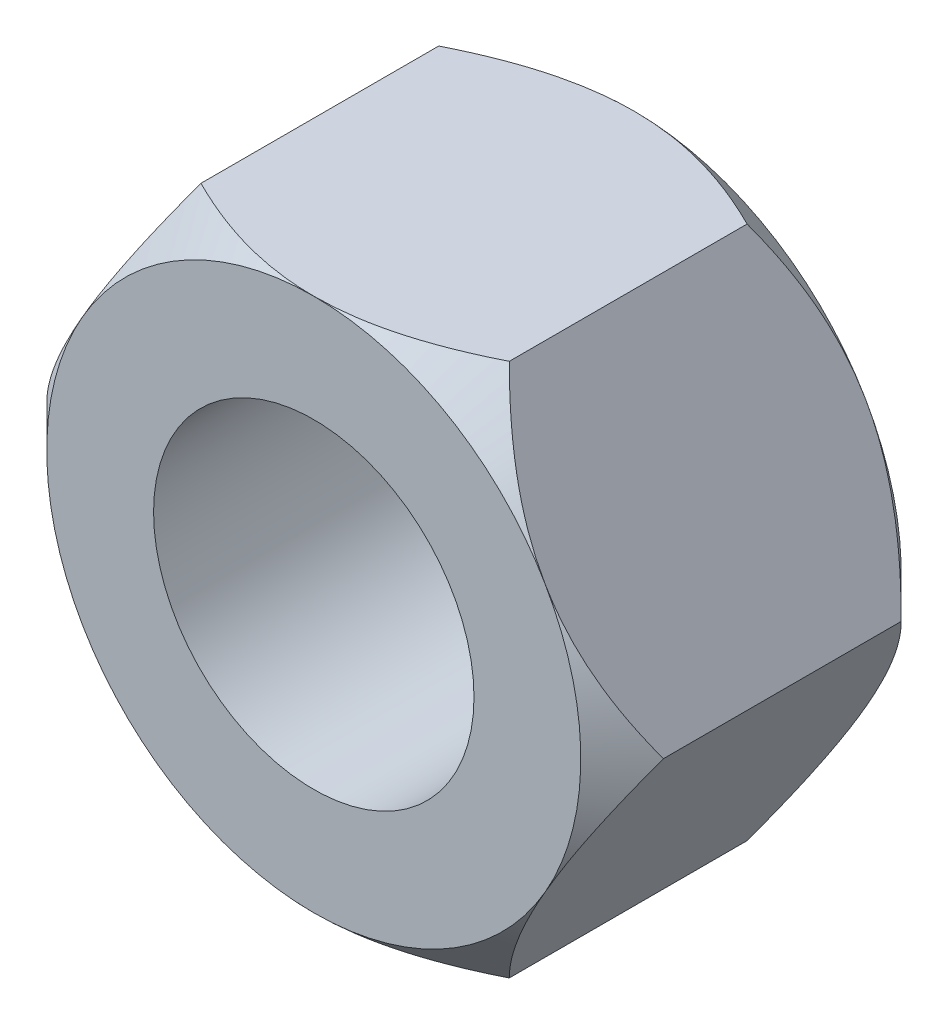
from build123d import *

# Parameters (mm, degrees)
SKETCH1_R           = 4.5
BOSS_EXTRUDE2_DEPTH = 4.5
SKETCH4_OUTSIDE_W   = 42.244
SKETCH4_OUTSIDE_H   = 39.924
SKETCH4_OUTSIDE_R   = 7.5
CUT_EXTRUDE2_DEPTH  = 9
CUT_EXTRUDE2_TAPER  = 45


with BuildPart() as part:
    # Sketch1 → Boss-Extrude2 (new body, symmetric)
    with BuildSketch(Plane.XY):
        Polygon((-4.330127019, 7.5), (-8.660254038, 0), (-4.330127019, -7.5), (4.330127019, -7.5), (8.660254038, 0), (4.330127019, 7.5), align=None)
        Circle(SKETCH1_R, mode=Mode.SUBTRACT)
    extrude(amount=BOSS_EXTRUDE2_DEPTH, both=True)

    # Sketch4 outside → Cut-Extrude2 (cut)
    with BuildSketch(Plane.XY.offset(4.5)):
        Rectangle(SKETCH4_OUTSIDE_W, SKETCH4_OUTSIDE_H)
        Circle(SKETCH4_OUTSIDE_R, mode=Mode.SUBTRACT)
    cut_extrude2 = extrude(amount=-CUT_EXTRUDE2_DEPTH, taper=CUT_EXTRUDE2_TAPER, mode=Mode.SUBTRACT)

    # Mirror3: Cut-Extrude2 across plane
    add(cut_extrude2.mirror(Plane.XY), mode=Mode.SUBTRACT)


solid = part.part
